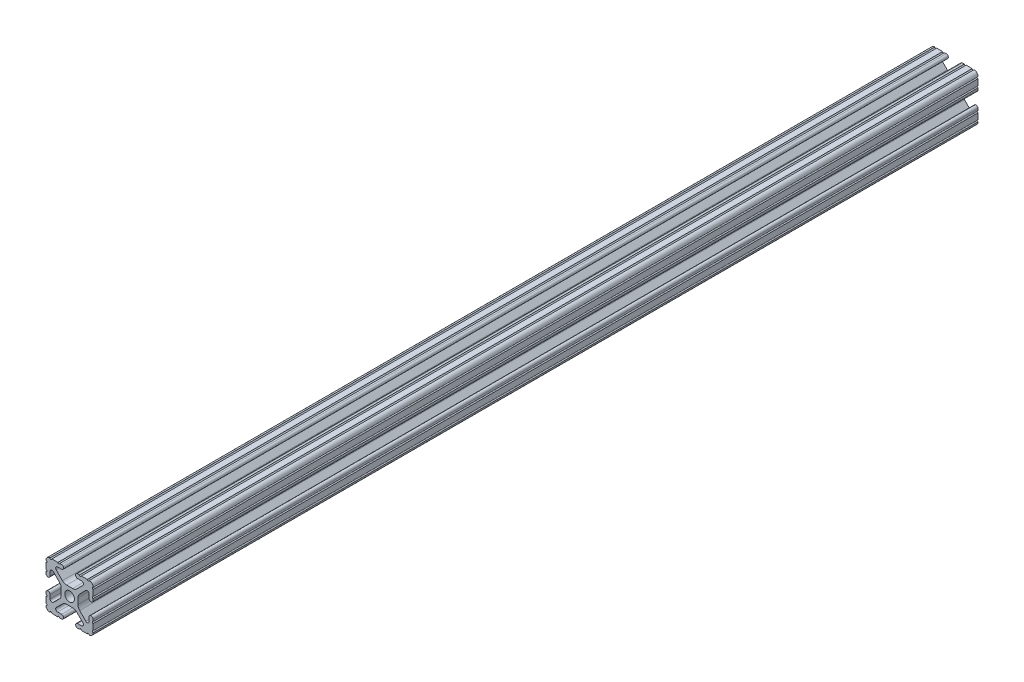
from build123d import *

# Parameters (mm, degrees)
SKETCH1_R           = 2.6035
BOSS_EXTRUDE1_DEPTH = 238.125


with BuildPart() as part:
    # Sketch1 → Boss-Extrude1 (new body, symmetric)
    with BuildSketch(Plane(origin=(0, 0, -450.85), x_dir=(-1, 0, 0), z_dir=(0, 0, -1))):
        with BuildLine():
            Line((12.7, -9.5504), (12.7, -6.3330836))
            ThreePointArc((12.7, -6.3330836), (12.192, -5.8250836), (12.7, -5.3170836))
            Line((12.7, -5.3170836), (12.7, -4.3434))
            ThreePointArc((12.7, -4.3434), (11.5951, -3.2385), (10.4902, -4.3434))
            Line((10.4902, -4.3434), (10.4902, -6.474794456))
            ThreePointArc((10.4902, -6.474794456), (9.863006367, -7.413456061), (8.75577951, -7.193214945))
            Line((8.75577951, -7.193214945), (5.42573597, -3.863171405))
            ThreePointArc((5.42573597, -3.863171405), (4.737482484, -2.833127272), (4.4958, -1.618107374))
            Line((4.4958, -1.618107374), (4.4958, 1.618107374))
            ThreePointArc((4.4958, 1.618107374), (4.737482484, 2.833127272), (5.42573597, 3.863171405))
            Line((5.42573597, 3.863171405), (8.75577951, 7.193214945))
            ThreePointArc((8.75577951, 7.193214945), (9.863006367, 7.413456061), (10.4902, 6.474794456))
            Line((10.4902, 6.474794456), (10.4902, 4.343399971))
            ThreePointArc((10.4902, 4.343399971), (11.5951, 3.238499971), (12.7, 4.343399971))
            Line((12.7, 4.343399971), (12.7, 5.3170836))
            ThreePointArc((12.7, 5.3170836), (12.192, 5.8250836), (12.7, 6.3330836))
            Line((12.7, 6.3330836), (12.7, 9.5504))
            ThreePointArc((12.7, 9.5504), (12.192000006, 10.058323491), (12.699846982, 10.566399977))
            ThreePointArc((12.699846982, 10.566399977), (12.082522516, 12.082522516), (10.566399977, 12.699846982))
            ThreePointArc((10.566399977, 12.699846982), (10.058323491, 12.192000006), (9.5504, 12.7))
            Line((9.5504, 12.7), (6.3330836, 12.7))
            ThreePointArc((6.3330836, 12.7), (5.8250836, 12.192), (5.3170836, 12.7))
            Line((5.3170836, 12.7), (4.3434, 12.7))
            ThreePointArc((4.3434, 12.7), (3.2385, 11.5951), (4.3434, 10.4902))
            Line((4.3434, 10.4902), (6.474794456, 10.4902))
            ThreePointArc((6.474794456, 10.4902), (7.413456061, 9.863006367), (7.193214945, 8.75577951))
            Line((7.193214945, 8.75577951), (3.863171405, 5.42573597))
            ThreePointArc((3.863171405, 5.42573597), (2.833127272, 4.737482484), (1.618107374, 4.4958))
            Line((1.618107374, 4.4958), (-1.618107374, 4.4958))
            ThreePointArc((-1.618107374, 4.4958), (-2.833127272, 4.737482484), (-3.863171405, 5.42573597))
            Line((-3.863171405, 5.42573597), (-7.193214945, 8.75577951))
            ThreePointArc((-7.193214945, 8.75577951), (-7.413456061, 9.863006367), (-6.474794456, 10.4902))
            Line((-6.474794456, 10.4902), (-4.343399971, 10.4902))
            ThreePointArc((-4.343399971, 10.4902), (-3.238499971, 11.5951), (-4.343399971, 12.7))
            Line((-4.343399971, 12.7), (-5.3170836, 12.7))
            ThreePointArc((-5.3170836, 12.7), (-5.8250836, 12.192), (-6.3330836, 12.7))
            Line((-6.3330836, 12.7), (-9.5504, 12.7))
            ThreePointArc((-9.5504, 12.7), (-10.058323491, 12.192000006), (-10.566399977, 12.699846982))
            ThreePointArc((-10.566399977, 12.699846982), (-12.082522516, 12.082522516), (-12.699846982, 10.566399977))
            ThreePointArc((-12.699846982, 10.566399977), (-12.192000006, 10.058323491), (-12.7, 9.5504))
            Line((-12.7, 9.5504), (-12.7, 6.3330836))
            ThreePointArc((-12.7, 6.3330836), (-12.192, 5.8250836), (-12.7, 5.3170836))
            Line((-12.7, 5.3170836), (-12.7, 4.3434))
            ThreePointArc((-12.7, 4.3434), (-11.5951, 3.2385), (-10.4902, 4.3434))
            Line((-10.4902, 4.3434), (-10.4902, 6.474794456))
            ThreePointArc((-10.4902, 6.474794456), (-9.863006367, 7.413456061), (-8.75577951, 7.193214945))
            Line((-8.75577951, 7.193214945), (-5.42573597, 3.863171405))
            ThreePointArc((-5.42573597, 3.863171405), (-4.737482484, 2.833127272), (-4.4958, 1.618107374))
            Line((-4.4958, 1.618107374), (-4.4958, -1.618107374))
            ThreePointArc((-4.4958, -1.618107374), (-4.737482484, -2.833127272), (-5.42573597, -3.863171405))
            Line((-5.42573597, -3.863171405), (-8.75577951, -7.193214945))
            ThreePointArc((-8.75577951, -7.193214945), (-9.863006367, -7.413456061), (-10.4902, -6.474794456))
            Line((-10.4902, -6.474794456), (-10.4902, -4.343399971))
            ThreePointArc((-10.4902, -4.343399971), (-11.5951, -3.238499971), (-12.7, -4.343399971))
            Line((-12.7, -4.343399971), (-12.7, -5.3170836))
            ThreePointArc((-12.7, -5.3170836), (-12.192, -5.8250836), (-12.7, -6.3330836))
            Line((-12.7, -6.3330836), (-12.7, -9.5504))
            ThreePointArc((-12.7, -9.5504), (-12.192000006, -10.058323491), (-12.699846982, -10.566399977))
            ThreePointArc((-12.699846982, -10.566399977), (-12.082522516, -12.082522516), (-10.566399977, -12.699846982))
            ThreePointArc((-10.566399977, -12.699846982), (-10.058323491, -12.192000006), (-9.5504, -12.7))
            Line((-9.5504, -12.7), (-6.3330836, -12.7))
            ThreePointArc((-6.3330836, -12.7), (-5.8250836, -12.192), (-5.3170836, -12.7))
            Line((-5.3170836, -12.7), (-4.3434, -12.7))
            ThreePointArc((-4.3434, -12.7), (-3.2385, -11.5951), (-4.3434, -10.4902))
            Line((-4.3434, -10.4902), (-6.474794456, -10.4902))
            ThreePointArc((-6.474794456, -10.4902), (-7.413456061, -9.863006367), (-7.193214945, -8.75577951))
            Line((-7.193214945, -8.75577951), (-3.863171405, -5.42573597))
            ThreePointArc((-3.863171405, -5.42573597), (-2.833127272, -4.737482484), (-1.618107374, -4.4958))
            Line((-1.618107374, -4.4958), (1.618107374, -4.4958))
            ThreePointArc((1.618107374, -4.4958), (2.833127272, -4.737482484), (3.863171405, -5.42573597))
            Line((3.863171405, -5.42573597), (7.193214945, -8.75577951))
            ThreePointArc((7.193214945, -8.75577951), (7.413456061, -9.863006367), (6.474794456, -10.4902))
            Line((6.474794456, -10.4902), (4.343399971, -10.4902))
            ThreePointArc((4.343399971, -10.4902), (3.238499971, -11.5951), (4.343399971, -12.7))
            Line((4.343399971, -12.7), (5.3170836, -12.7))
            ThreePointArc((5.3170836, -12.7), (5.8250836, -12.192), (6.3330836, -12.7))
            Line((6.3330836, -12.7), (9.5504, -12.7))
            ThreePointArc((9.5504, -12.7), (10.058323491, -12.192000006), (10.566399977, -12.699846982))
            ThreePointArc((10.566399977, -12.699846982), (12.082522516, -12.082522516), (12.699846982, -10.566399977))
            ThreePointArc((12.699846982, -10.566399977), (12.192000006, -10.058323491), (12.7, -9.5504))
        make_face()
        Circle(SKETCH1_R, mode=Mode.SUBTRACT)
    extrude(amount=BOSS_EXTRUDE1_DEPTH, both=True)


solid = part.part
